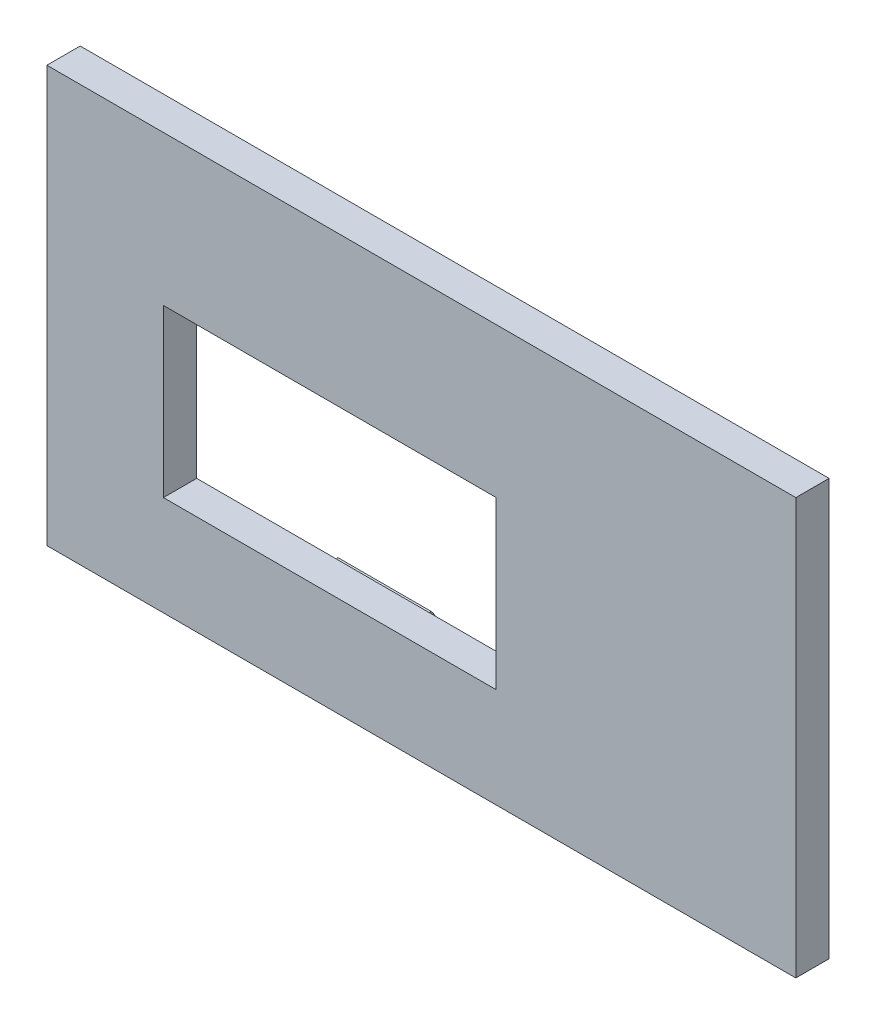
from build123d import *

# Parameters (mm, degrees)
Y_KSEKLIK_EKSTR_ZYON1_DEPTH = 10
BO_ALTMA1_T                 = -2
IZIM2_W                     = 45
IZIM2_H                     = 25
KES_EKSTR_ZYON1_DEPTH       = 8
IZIM3_W                     = 20
IZIM3_H                     = 10
KES_EKSTR_ZYON2_DEPTH       = 6
Y_KSEKLIK_EKSTR_ZYON2_DEPTH = 28.698952
KES_EKSTR_ZYON3_DEPTH       = 2.5


with BuildPart() as part:
    # Çizim1 → Yükseklik-Ekstrüzyon1 (new body)
    with BuildSketch(Plane.XY):
        Polygon((22.5, 11.5), (22.5, -11.5), (-22.5, -11.5), (-22.5, 11.5), (-22.5, 13.5), (22.5, 13.5), align=None)
    extrude(amount=Y_KSEKLIK_EKSTR_ZYON1_DEPTH)

    # İç Boşaltma1
    bo_altma1_openings = [part.faces().sort_by_distance(p)[0] for p in [
        (0, -11.5, 5),
        (-22.5, 1, 5),
        (22.5, 1, 5),
    ]]
    offset(amount=BO_ALTMA1_T, openings=bo_altma1_openings, kind=Kind.INTERSECTION)

    # Çizim2 → Kes-Ekstrüzyon1 (cut)
    with BuildSketch(Plane.XY):
        with Locations((0, 1)):
            Rectangle(IZIM2_W, IZIM2_H)
    extrude(amount=KES_EKSTR_ZYON1_DEPTH, mode=Mode.SUBTRACT)

    # Çizim3 → Kes-Ekstrüzyon2 (cut)
    with BuildSketch(Plane(origin=(0, 0, 8), x_dir=(-1, 0, 0), z_dir=(0, 0, -1))):
        with Locations((5.5, -0.5)):
            Rectangle(IZIM3_W, IZIM3_H)
    extrude(amount=-KES_EKSTR_ZYON2_DEPTH, mode=Mode.SUBTRACT)

    # Çizim4 → Kes-Döndür1 (revolve, cut)
    with BuildSketch(Plane(origin=(0, 0, 8), x_dir=(-1, 0, 0), z_dir=(0, 0, -1))):
        Polygon((-20.60881654, 7.5), (-20.60881654, 8.5), (-8.5, 8.5), (8.090135665, 8.5), (8.090135665, 7.5), align=None)
    kes_d_nd_r1 = revolve(axis=Axis((20.60881654, 7.5, 8), (-1, 0, 0)), mode=Mode.SUBTRACT)

    # Çizim6 → Yükseklik-Ekstrüzyon2 (add)
    with BuildSketch(Plane(origin=(-8.090135665, 0, 0), x_dir=(0, 0, -1), z_dir=(1, 0, 0))):
        with BuildLine():
            Line((-8, 9), (-8, 8.5))
            ThreePointArc((-8, 8.5), (-7.076120467, 7.882683432), (-7.292893219, 6.792893219))
            Line((-7.292893219, 6.792893219), (-6.939339828, 6.439339828))
            ThreePointArc((-6.939339828, 6.439339828), (-6.614180701, 8.074025149), (-8, 9))
        make_face()
    y_kseklik_ekstr_zyon2 = extrude(amount=Y_KSEKLIK_EKSTR_ZYON2_DEPTH)

    # Çizim8 → Kes-Ekstrüzyon3 (cut, symmetric)
    with BuildSketch(Plane(origin=(0, 0, 0), x_dir=(0, 0, -1), z_dir=(1, 0, 0))):
        with BuildLine():
            Line((-7.292893219, 6.792893219), (-6.939339828, 6.439339828))
            ThreePointArc((-6.939339828, 6.439339828), (-6.614180701, 8.074025149), (-8, 9))
            Line((-8, 9), (-8, 8.5))
            ThreePointArc((-8, 8.5), (-7.076120467, 7.882683432), (-7.292893219, 6.792893219))
        make_face()
    kes_ekstr_zyon3 = extrude(amount=KES_EKSTR_ZYON3_DEPTH, both=True, mode=Mode.SUBTRACT)

    # Aynalama1: Kes-Döndür1, Yükseklik-Ekstrüzyon2, Kes-Ekstrüzyon3 across plane
    add(kes_d_nd_r1.mirror(Plane.ZX), mode=Mode.SUBTRACT)
    add(y_kseklik_ekstr_zyon2.mirror(Plane.ZX))
    add(kes_ekstr_zyon3.mirror(Plane.ZX), mode=Mode.SUBTRACT)


solid = part.part
